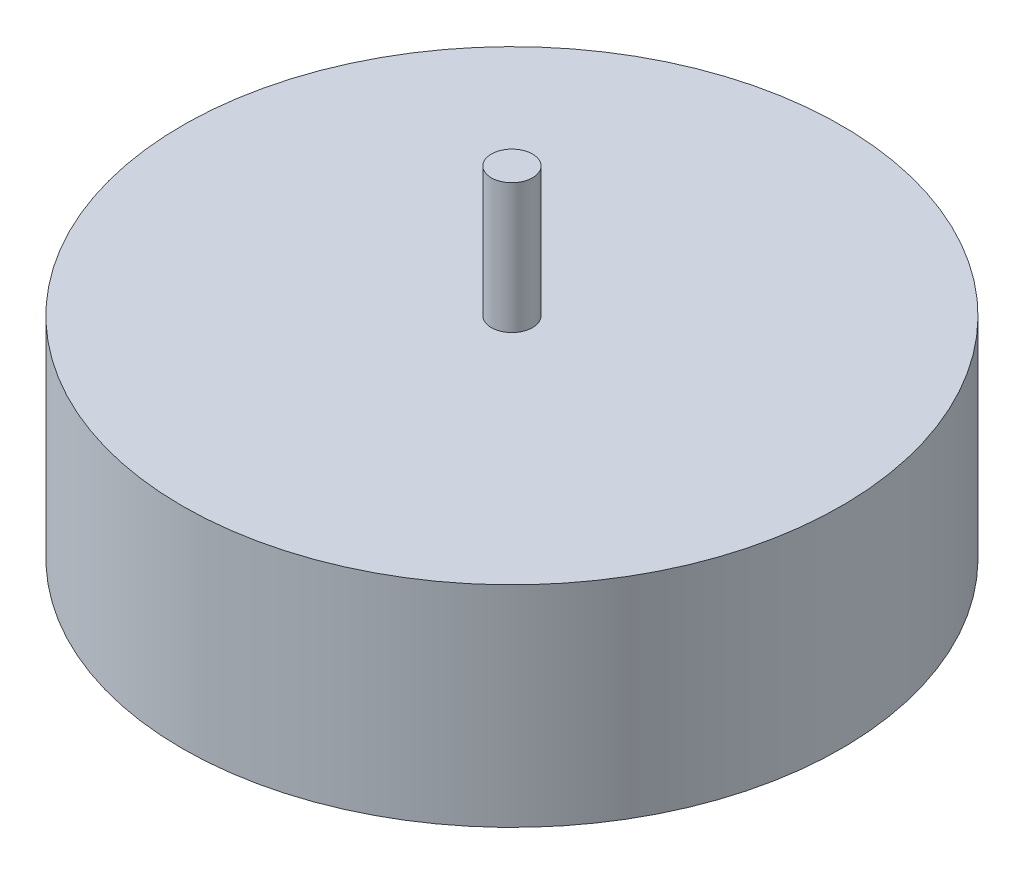
from build123d import *

# Parameters (mm, degrees)
SKETCH1_R           = 127
BOSS_EXTRUDE1_DEPTH = 80.96
SKETCH2_R           = 7.9375
BOSS_EXTRUDE2_DEPTH = 50


with BuildPart() as part:
    # Sketch1 → Boss-Extrude1 (new body)
    with BuildSketch(Plane(origin=(0, 0, 0), x_dir=(1, 0, 0), z_dir=(0, 1, 0))):
        Circle(SKETCH1_R)
    extrude(amount=BOSS_EXTRUDE1_DEPTH)

    # Sketch2 → Boss-Extrude2 (add)
    with BuildSketch(Plane(origin=(0, 80.96, 0), x_dir=(1, 0, 0), z_dir=(0, 1, 0))):
        Circle(SKETCH2_R)
    extrude(amount=BOSS_EXTRUDE2_DEPTH)


solid = part.part
